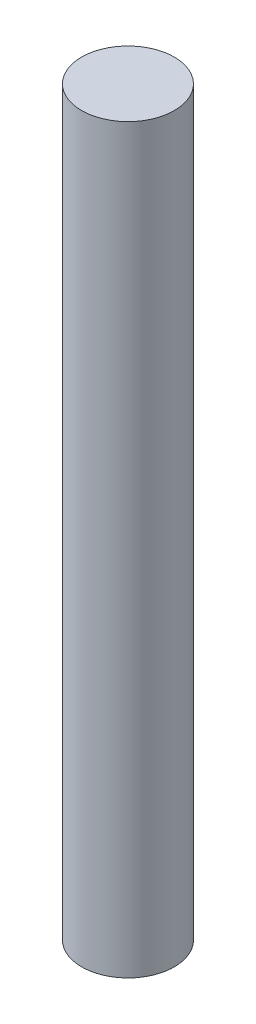
from build123d import *

# Parameters (mm, degrees)
SKETCH1_W = 9.525
SKETCH1_H = 152.4


with BuildPart() as part:
    # Sketch1 → Revolve1 (revolve)
    with BuildSketch(Plane.XY):
        with Locations((4.7625, 0)):
            Rectangle(SKETCH1_W, SKETCH1_H)
    revolve(axis=Axis((0, 101.6, 0), (0, -1, 0)))


solid = part.part
